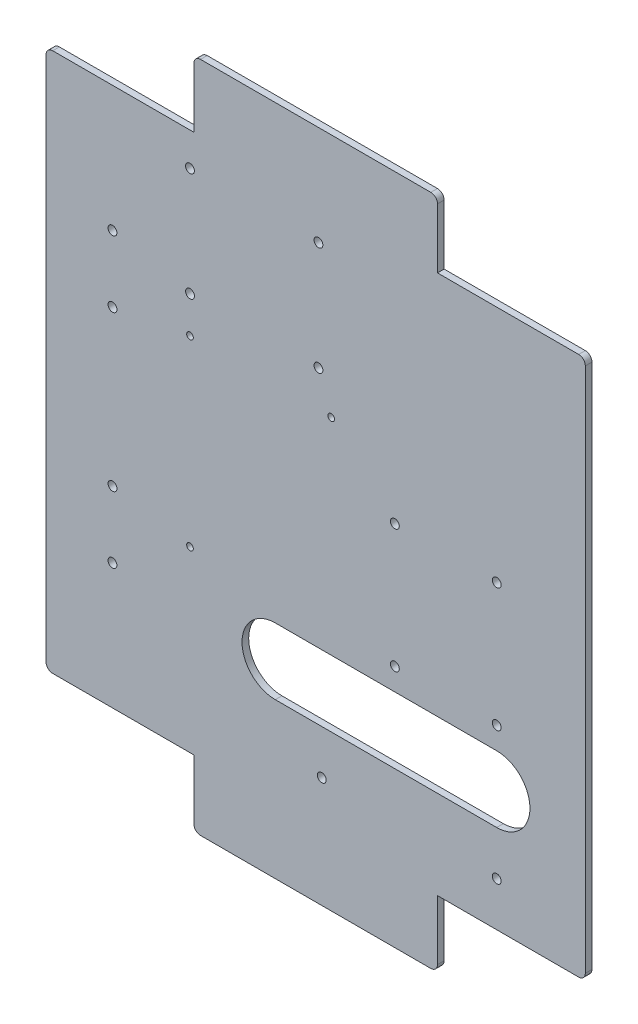
from build123d import *

# Parameters (mm, degrees)
BASE_DEPTH              = 3
CONG_1_R                = 3
ENL_V_MAT_EXTRU_1_DEPTH = 4
CONG_2_R                = 3
ESQUISSE26_R            = 2
ENL_V_MAT_EXTRU_2_DEPTH = 4
ESQUISSE27_R            = 2
ENL_V_MAT_EXTRU_3_DEPTH = 4
ESQUISSE28_R            = 1.5
ENL_V_MAT_EXTRU_4_DEPTH = 4
ESQUISSE29_R            = 2
ENL_V_MAT_EXTRU_5_DEPTH = 4
ESQUISSE30_R            = 2
ENL_V_MAT_EXTRU_6_DEPTH = 4
ENL_V_MAT_EXTRU_7_DEPTH = 4


with BuildPart() as part:
    # Esquisse1 → Base (new body)
    with BuildSketch(Plane.XY):
        Polygon((0, 0), (-200, 0), (-224.748737342, 24.748737342), (-224.748737342, 284.748737342), (-200, 309.497474683), (0, 309.497474683), (24.748737342, 284.748737342), (24.748737342, 24.748737342), align=None)
    extrude(amount=BASE_DEPTH)

    # Congé1
    cong_1_edges = [part.edges().sort_by_distance(p)[0] for p in [
        (0, 0, 1.5),
        (-200, 0, 1.5),
        (-224.748737342, 24.748737342, 1.5),
        (-224.748737342, 284.748737342, 1.5),
        (-200, 309.497474683, 1.5),
        (0, 309.497474683, 1.5),
        (24.748737342, 284.748737342, 1.5),
        (24.748737342, 24.748737342, 1.5),
    ]]
    fillet(cong_1_edges, radius=CONG_1_R)

    # Esquisse25 → Enlèv. mat.-Extru.1 (cut, through all)
    with BuildSketch(Plane(origin=(0, 0, 0), x_dir=(-1, 0, 0), z_dir=(0, 0, -1))):
        Polygon((-24.748737342, 33), (-24.748737342, 0), (45, 0), (155, 0), (224.748737342, 0), (224.748737342, 33), (224.748737342, 276.497474683), (224.748737342, 309.497474683), (155, 309.497474683), (45, 309.497474683), (-24.748737342, 309.497474683), (-24.748737342, 276.497474683), align=None)
        Polygon((-21.748737342, 33), (45, 33), (45, 3), (155, 3), (155, 33), (221.748737342, 33), (221.748737342, 276.497474683), (155, 276.497474683), (155, 306.497474683), (45, 306.497474683), (45, 276.497474683), (-21.748737342, 276.497474683), align=None, mode=Mode.SUBTRACT)
    extrude(amount=-ENL_V_MAT_EXTRU_1_DEPTH, mode=Mode.SUBTRACT)

    # Congé2
    cong_2_edges = [part.edges().sort_by_distance(p)[0] for p in [
        (21.748737342, 33, 1.5),
        (21.748737342, 276.497474683, 1.5),
        (-45, 306.497474683, 1.5),
        (-155, 306.497474683, 1.5),
        (-221.748737342, 276.497474683, 1.5),
        (-221.748737342, 33, 1.5),
        (-155, 3, 1.5),
        (-45, 3, 1.5),
    ]]
    fillet(cong_2_edges, radius=CONG_2_R)

    # Esquisse26 → Enlèv. mat.-Extru.2 (cut, through all)
    with BuildSketch(Plane(origin=(0, 0, 0), x_dir=(-1, 0, 0), z_dir=(0, 0, -1))):
        with Locations((191.748737342, 189.748737342)):
            Circle(ESQUISSE26_R)
        with Locations((191.748737342, 219.748737342)):
            Circle(ESQUISSE26_R)
        with Locations((191.748737342, 89.748737342)):
            Circle(ESQUISSE26_R)
        with Locations((191.748737342, 119.748737342)):
            Circle(ESQUISSE26_R)
    extrude(amount=-ENL_V_MAT_EXTRU_2_DEPTH, mode=Mode.SUBTRACT)

    # Esquisse27 → Enlèv. mat.-Extru.3 (cut, through all)
    with BuildSketch(Plane(origin=(0, 0, 0), x_dir=(-1, 0, 0), z_dir=(0, 0, -1))):
        with Locations((97.251262658, 53)):
            Circle(ESQUISSE27_R)
        with Locations((18.251262658, 53)):
            Circle(ESQUISSE27_R)
    extrude(amount=-ENL_V_MAT_EXTRU_3_DEPTH, mode=Mode.SUBTRACT)

    # Esquisse28 → Enlèv. mat.-Extru.4 (cut, through all)
    with BuildSketch(Plane(origin=(0, 0, 0), x_dir=(-1, 0, 0), z_dir=(0, 0, -1))):
        with Locations((156.748737342, 195.986237342)):
            Circle(ESQUISSE28_R)
        with Locations((92.998737342, 195.986237342)):
            Circle(ESQUISSE28_R)
        with Locations((156.748737342, 113.511237342)):
            Circle(ESQUISSE28_R)
    extrude(amount=-ENL_V_MAT_EXTRU_4_DEPTH, mode=Mode.SUBTRACT)

    # Esquisse29 → Enlèv. mat.-Extru.5 (cut, through all)
    with BuildSketch(Plane(origin=(0, 0, 0), x_dir=(-1, 0, 0), z_dir=(0, 0, -1))):
        with Locations((156.748737342, 212.497474683)):
            Circle(ESQUISSE29_R)
        with Locations((98.748737342, 212.497474683)):
            Circle(ESQUISSE29_R)
        with Locations((98.748737342, 261.497474683)):
            Circle(ESQUISSE29_R)
        with Locations((156.748737342, 261.497474683)):
            Circle(ESQUISSE29_R)
    extrude(amount=-ENL_V_MAT_EXTRU_5_DEPTH, mode=Mode.SUBTRACT)

    # Esquisse30 → Enlèv. mat.-Extru.6 (cut, through all)
    with BuildSketch(Plane(origin=(0, 0, 0), x_dir=(-1, 0, 0), z_dir=(0, 0, -1))):
        with Locations((64.251262658, 113)):
            Circle(ESQUISSE30_R)
        with Locations((18.251262658, 113)):
            Circle(ESQUISSE30_R)
        with Locations((18.251262658, 168.8)):
            Circle(ESQUISSE30_R)
        with Locations((64.251262658, 168.8)):
            Circle(ESQUISSE30_R)
    extrude(amount=-ENL_V_MAT_EXTRU_6_DEPTH, mode=Mode.SUBTRACT)

    # Esquisse31 → Enlèv. mat.-Extru.7 (cut, through all)
    with BuildSketch(Plane(origin=(0, 0, 0), x_dir=(-1, 0, 0), z_dir=(0, 0, -1))):
        with BuildLine():
            Line((118.251262658, 73), (18.251262658, 73))
            ThreePointArc((18.251262658, 73), (3.251262658, 88), (18.251262658, 103))
            Line((18.251262658, 103), (118.251262658, 103))
            ThreePointArc((118.251262658, 103), (133.251262658, 88), (118.251262658, 73))
        make_face()
    extrude(amount=-ENL_V_MAT_EXTRU_7_DEPTH, mode=Mode.SUBTRACT)


solid = part.part
